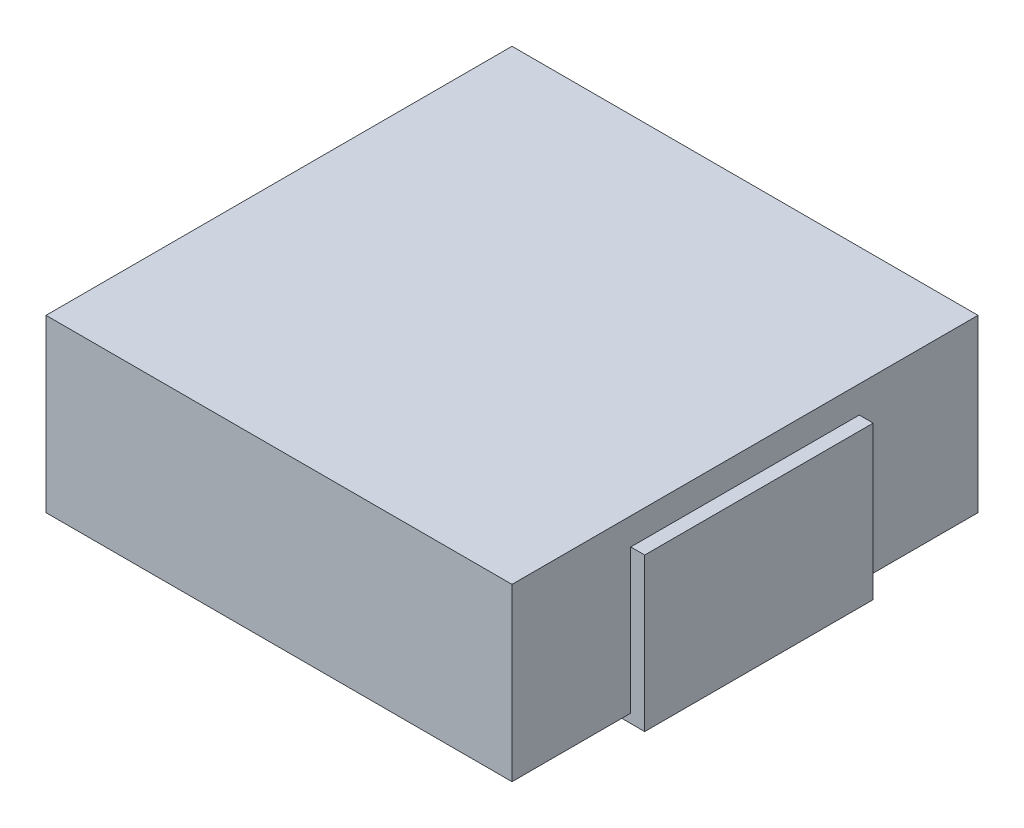
from build123d import *

# Parameters (mm, degrees)
EXTRUDE_START     = 0.1
SKETCH_1_W        = 5.18
SKETCH_1_H        = 5.18
EXTRUDE_1_DEPTH   = 1.9
SKETCH_2_W        = 1.02
SKETCH_2_H        = 2.54
EXTRUDE_2_DEPTH   = 1.7
EXTRUDE_2_2_DEPTH = 1.7


with BuildPart() as part:
    # Эскиз1 → Бобышка-Вытянуть1 (new body)
    with BuildSketch(Plane(origin=(0, 0, 0), x_dir=(1, 0, 0), z_dir=(0, 1, 0)).offset(EXTRUDE_START)):
        Rectangle(SKETCH_1_W, SKETCH_1_H)
    extrude(amount=EXTRUDE_1_DEPTH)


with BuildPart() as body_2:
    # Эскиз2 → Бобышка-Вытянуть2 (new body)
    with BuildSketch(Plane(origin=(0, 0, 0), x_dir=(1, 0, 0), z_dir=(0, 1, 0))):
        with Locations((-2.235, 0)):
            Rectangle(SKETCH_2_W, SKETCH_2_H)
    extrude(amount=EXTRUDE_2_DEPTH)


with BuildPart() as body_3:
    # Эскиз2 → Extrude 2 2 (new body)
    with BuildSketch(Plane(origin=(0, 0, 0), x_dir=(1, 0, 0), z_dir=(0, 1, 0))):
        with Locations((2.235, 0)):
            Rectangle(SKETCH_2_W, SKETCH_2_H)
    extrude(amount=EXTRUDE_2_2_DEPTH)


solid = Compound([part.part, body_2.part, body_3.part])
